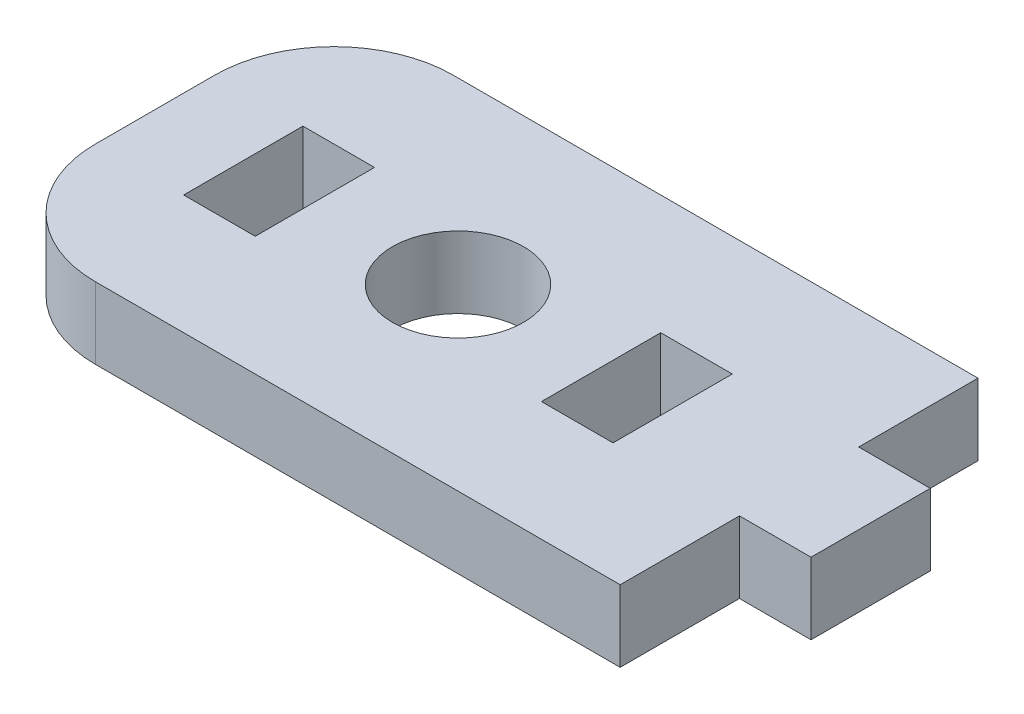
from build123d import *

# Parameters (mm, degrees)
SKETCH1_R           = 2.75
SKETCH1_W           = 3
SKETCH1_H           = 5
BOSS_EXTRUDE1_DEPTH = 3
FILLET1_R           = 5


with BuildPart() as part:
    # Sketch1 → Boss-Extrude1 (new body)
    with BuildSketch(Plane(origin=(0, 0, 0), x_dir=(1, 0, 0), z_dir=(0, 1, 0))):
        Polygon((-21.821592901, -5), (-21.821592901, 10), (5.178407099, 10), (5.178407099, 5), (8.178407099, 5), (8.178407099, 0), (5.178407099, 0), (5.178407099, -5), align=None)
        with Locations((-9.121592901, 2.5)):
            Circle(SKETCH1_R, mode=Mode.SUBTRACT)
        with Locations((-16.621592901, 2.5)):
            Rectangle(SKETCH1_W, SKETCH1_H, mode=Mode.SUBTRACT)
        with Locations((-1.621592901, 2.5)):
            Rectangle(SKETCH1_W, SKETCH1_H, mode=Mode.SUBTRACT)
    extrude(amount=BOSS_EXTRUDE1_DEPTH)

    # Fillet1
    fillet1_edges = [part.edges().sort_by_distance(p)[0] for p in [
        (-21.821592901, 1.5, 5),
        (-21.821592901, 1.5, -10),
    ]]
    fillet(fillet1_edges, radius=FILLET1_R)


solid = part.part
